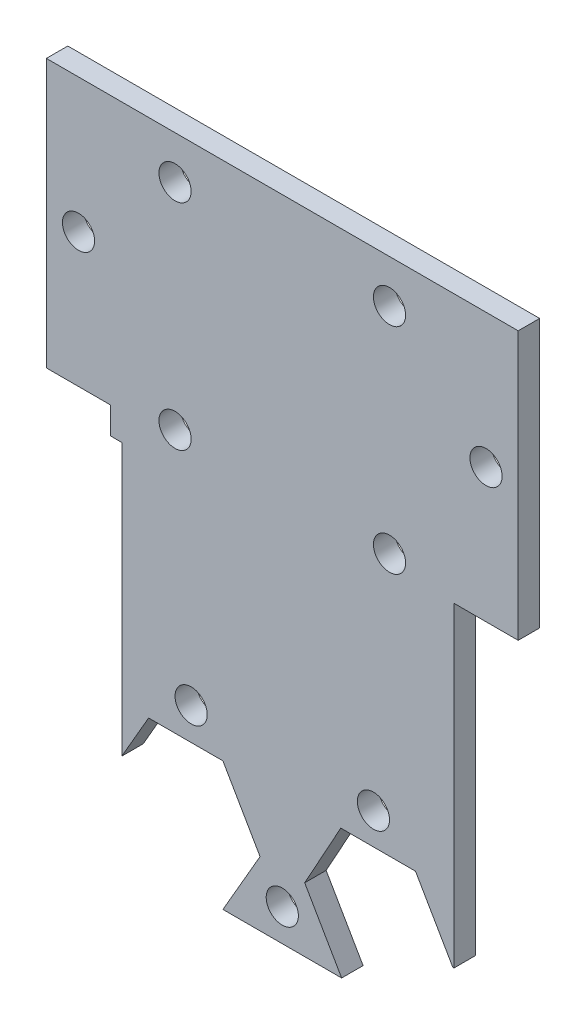
from build123d import *

# Parameters (mm, degrees)
SKETCH1_R           = 1.500000001
SKETCH1_R_2         = 1.5
BOSS_EXTRUDE2_DEPTH = 2
SKETCH10_W          = 6
SKETCH10_H          = 25
SKETCH10_R          = 1.5
BOSS_EXTRUDE8_DEPTH = 2
CUT_EXTRUDE1_DEPTH  = 10


with BuildPart() as part:
    # Sketch1 → Boss-Extrude2 (new body)
    with BuildSketch(Plane.XY):
        Polygon((16, 14), (-16, 14), (-16, -13.5), (-14.969293645, -13.5), (-14.969293645, -38.839119879), (-12.464101615, -34.5), (-5.535898385, -34.5), (-2.07179677, -40.5), (-5.535898385, -46.5), (5.535898385, -46.5), (2.090853862, -40.533007852), (5.457729166, -34.432863746), (12.425340481, -34.432863746), (15.909146138, -40.466992148), (15, -42.114193768), (15, -46.5), (16, -46.5), align=None)
        with Locations((-10, -10)):
            Circle(SKETCH1_R, mode=Mode.SUBTRACT)
        with Locations((10, -10)):
            Circle(SKETCH1_R, mode=Mode.SUBTRACT)
        with Locations((-10, 10)):
            Circle(SKETCH1_R, mode=Mode.SUBTRACT)
        with Locations((10, 10)):
            Circle(SKETCH1_R, mode=Mode.SUBTRACT)
        with Locations((8.5, -31.5)):
            Circle(SKETCH1_R_2, mode=Mode.SUBTRACT)
        with Locations((0, -43.5)):
            Circle(SKETCH1_R_2, mode=Mode.SUBTRACT)
        with Locations((-8.5, -31.5)):
            Circle(SKETCH1_R_2, mode=Mode.SUBTRACT)
    extrude(amount=BOSS_EXTRUDE2_DEPTH)

    # Sketch10 → Boss-Extrude8 (add)
    with BuildSketch(Plane(origin=(0, 0, 0), x_dir=(-1, 0, 0), z_dir=(0, 0, -1))):
        with Locations((19, 1.5)):
            Rectangle(SKETCH10_W, SKETCH10_H)
        with Locations((19, 1.5)):
            Circle(SKETCH10_R, mode=Mode.SUBTRACT)
        with Locations((-19, 1.5)):
            Rectangle(SKETCH10_W, SKETCH10_H)
        with Locations((-19, 1.5)):
            Circle(SKETCH10_R, mode=Mode.SUBTRACT)
    extrude(amount=-BOSS_EXTRUDE8_DEPTH)

    # Sketch5 → Cut-Extrude1 (cut)
    with BuildSketch(Plane.XY.offset(2)):
        Polygon((15, -42.114193768), (15.909146138, -40.466992148), (10.36687247, -40.472738184), (10.36687247, -46.5), (15, -46.5), align=None)
        Polygon((16, -40.466897954), (15.909146138, -40.466992148), (15, -42.114193768), (15, -46.5), (16, -46.5), align=None)
        Polygon((17.825288522, -40.465005559), (16, -40.466897954), (16, -46.5), (17.916172301, -46.5), align=None)
    extrude(amount=-CUT_EXTRUDE1_DEPTH, mode=Mode.SUBTRACT)


solid = part.part
